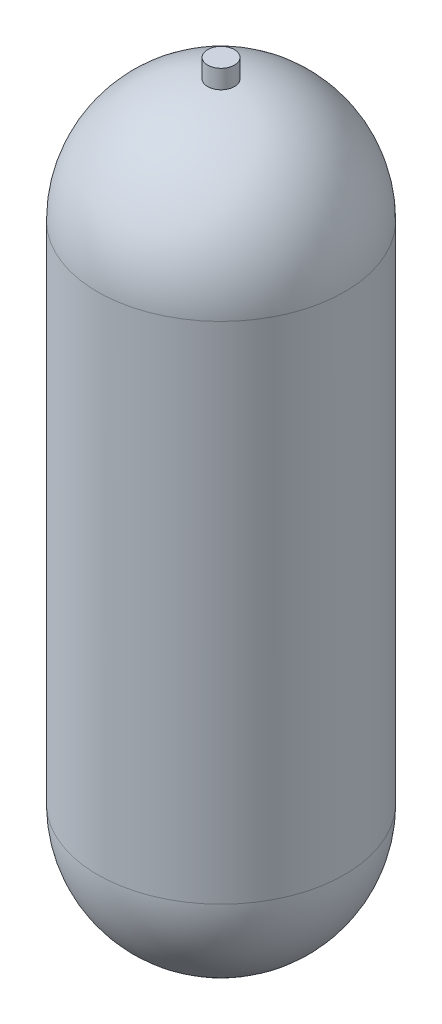
from build123d import *

# Parameters (mm, degrees)
SKETCH2_R                       = 9.525
BOSS_EXTRUDE1_DEPTH             = 12.7
BOSS_EXTRUDE1_DIRECTION_2_REACH = 535.4


with BuildPart() as part:
    # Sketch1 → Revolve1 (revolve)
    with BuildSketch(Plane.XY):
        with BuildLine():
            Line((87.63, 445.77), (87.63, 87.63))
            ThreePointArc((87.63, 87.63), (61.963767, 25.666233), (0, 0))
            Line((0, 0), (0, 3.175))
            ThreePointArc((0, 3.175), (59.718703, 27.911297), (84.455, 87.63))
            Line((84.455, 87.63), (84.455, 445.77))
            ThreePointArc((84.455, 445.77), (59.718703, 505.488703), (0, 530.225))
            Line((0, 530.225), (0, 533.4))
            ThreePointArc((0, 533.4), (61.963767, 507.733767), (87.63, 445.77))
        make_face()
    revolve(axis=Axis((0, 533.4, 0), (0, 1, 0)))

    # Sketch2 → Boss-Extrude1 (add)
    with BuildSketch(Plane(origin=(0, 533.4, 0), x_dir=(1, 0, 0), z_dir=(0, 1, 0))):
        Circle(SKETCH2_R)
    extrude(amount=BOSS_EXTRUDE1_DEPTH)

    # Sketch2 → Boss-Extrude1 direction 2 (add, up to next)
    with BuildSketch(Plane(origin=(0, 533.4, 0), x_dir=(1, 0, 0), z_dir=(0, 1, 0)), mode=Mode.PRIVATE) as boss_extrude1_direction_2_sk1:
        Circle(SKETCH2_R)
    boss_extrude1_direction_2_tool1 = extrude(boss_extrude1_direction_2_sk1.sketch, amount=-BOSS_EXTRUDE1_DIRECTION_2_REACH, mode=Mode.PRIVATE) - part.part
    add(boss_extrude1_direction_2_tool1.solids().sort_by_distance((0, 533.4, 0))[0])


solid = part.part
